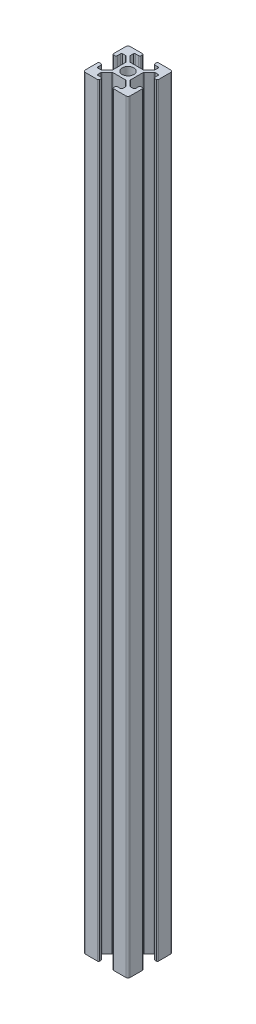
from build123d import *

# Parameters (mm, degrees)
SKETCH1_R           = 2.6
BOSS_EXTRUDE1_DEPTH = 340


with BuildPart() as part:
    # Sketch1 → Boss-Extrude1 (new body)
    with BuildSketch(Plane(origin=(0, 170, 0), x_dir=(1, 0, 0), z_dir=(0, 1, 0))):
        with BuildLine():
            Line((-3.1, 8.85), (-3.1, 9.5))
            ThreePointArc((-3.1, 9.5), (-3.246446609, 9.853553391), (-3.6, 10))
            Line((-3.6, 10), (-9, 10))
            ThreePointArc((-9, 10), (-9.707106781, 9.707106781), (-10, 9))
            Line((-10, 9), (-10, 3.6))
            ThreePointArc((-10, 3.6), (-9.853553391, 3.246446609), (-9.5, 3.1))
            Line((-9.5, 3.1), (-8.85, 3.1))
            ThreePointArc((-8.85, 3.1), (-8.496446609, 3.246446609), (-8.35, 3.6))
            Line((-8.35, 3.6), (-8.35, 5))
            ThreePointArc((-8.35, 5), (-8.203553391, 5.353553391), (-7.85, 5.5))
            Line((-7.85, 5.5), (-6.626345597, 5.5))
            ThreePointArc((-6.626345597, 5.5), (-6.435003881, 5.461939766), (-6.272792206, 5.353553391))
            Line((-6.272792206, 5.353553391), (-4.046446609, 3.127207794))
            ThreePointArc((-4.046446609, 3.127207794), (-3.938060234, 2.964996119), (-3.9, 2.773654403))
            Line((-3.9, 2.773654403), (-3.9, -2.773654403))
            ThreePointArc((-3.9, -2.773654403), (-3.938060234, -2.964996119), (-4.046446609, -3.127207794))
            Line((-4.046446609, -3.127207794), (-6.272792206, -5.353553391))
            ThreePointArc((-6.272792206, -5.353553391), (-6.435003881, -5.461939766), (-6.626345597, -5.5))
            Line((-6.626345597, -5.5), (-7.85, -5.5))
            ThreePointArc((-7.85, -5.5), (-8.203553391, -5.353553391), (-8.35, -5))
            Line((-8.35, -5), (-8.35, -3.6))
            ThreePointArc((-8.35, -3.6), (-8.496446609, -3.246446609), (-8.85, -3.1))
            Line((-8.85, -3.1), (-9.5, -3.1))
            ThreePointArc((-9.5, -3.1), (-9.853553391, -3.246446609), (-10, -3.6))
            Line((-10, -3.6), (-10, -9))
            ThreePointArc((-10, -9), (-9.707106781, -9.707106781), (-9, -10))
            Line((-9, -10), (-3.6, -10))
            ThreePointArc((-3.6, -10), (-3.246446609, -9.853553391), (-3.1, -9.5))
            Line((-3.1, -9.5), (-3.1, -8.85))
            ThreePointArc((-3.1, -8.85), (-3.246446609, -8.496446609), (-3.6, -8.35))
            Line((-3.6, -8.35), (-5, -8.35))
            ThreePointArc((-5, -8.35), (-5.353553391, -8.203553391), (-5.5, -7.85))
            Line((-5.5, -7.85), (-5.5, -6.626345597))
            ThreePointArc((-5.5, -6.626345597), (-5.461939766, -6.435003881), (-5.353553391, -6.272792206))
            Line((-5.353553391, -6.272792206), (-3.127207794, -4.046446609))
            ThreePointArc((-3.127207794, -4.046446609), (-2.964996119, -3.938060234), (-2.773654403, -3.9))
            Line((-2.773654403, -3.9), (2.773654403, -3.9))
            ThreePointArc((2.773654403, -3.9), (2.964996119, -3.938060234), (3.127207794, -4.046446609))
            Line((3.127207794, -4.046446609), (5.353553391, -6.272792206))
            ThreePointArc((5.353553391, -6.272792206), (5.461939766, -6.435003881), (5.5, -6.626345597))
            Line((5.5, -6.626345597), (5.5, -7.85))
            ThreePointArc((5.5, -7.85), (5.353553391, -8.203553391), (5, -8.35))
            Line((5, -8.35), (3.6, -8.35))
            ThreePointArc((3.6, -8.35), (3.246446609, -8.496446609), (3.1, -8.85))
            Line((3.1, -8.85), (3.1, -9.5))
            ThreePointArc((3.1, -9.5), (3.246446609, -9.853553391), (3.6, -10))
            Line((3.6, -10), (9, -10))
            ThreePointArc((9, -10), (9.707106781, -9.707106781), (10, -9))
            Line((10, -9), (10, -3.6))
            ThreePointArc((10, -3.6), (9.853553391, -3.246446609), (9.5, -3.1))
            Line((9.5, -3.1), (8.85, -3.1))
            ThreePointArc((8.85, -3.1), (8.496446609, -3.246446609), (8.35, -3.6))
            Line((8.35, -3.6), (8.35, -5))
            ThreePointArc((8.35, -5), (8.203553391, -5.353553391), (7.85, -5.5))
            Line((7.85, -5.5), (6.626345597, -5.5))
            ThreePointArc((6.626345597, -5.5), (6.435003881, -5.461939766), (6.272792206, -5.353553391))
            Line((6.272792206, -5.353553391), (4.046446609, -3.127207794))
            ThreePointArc((4.046446609, -3.127207794), (3.938060234, -2.964996119), (3.9, -2.773654403))
            Line((3.9, -2.773654403), (3.9, 2.773654403))
            ThreePointArc((3.9, 2.773654403), (3.938060234, 2.964996119), (4.046446609, 3.127207794))
            Line((4.046446609, 3.127207794), (6.272792206, 5.353553391))
            ThreePointArc((6.272792206, 5.353553391), (6.435003881, 5.461939766), (6.626345597, 5.5))
            Line((6.626345597, 5.5), (7.85, 5.5))
            ThreePointArc((7.85, 5.5), (8.203553391, 5.353553391), (8.35, 5))
            Line((8.35, 5), (8.35, 3.6))
            ThreePointArc((8.35, 3.6), (8.496446609, 3.246446609), (8.85, 3.1))
            Line((8.85, 3.1), (9.5, 3.1))
            ThreePointArc((9.5, 3.1), (9.853553391, 3.246446609), (10, 3.6))
            Line((10, 3.6), (10, 9))
            ThreePointArc((10, 9), (9.707106781, 9.707106781), (9, 10))
            Line((9, 10), (3.6, 10))
            ThreePointArc((3.6, 10), (3.246446609, 9.853553391), (3.1, 9.5))
            Line((3.1, 9.5), (3.1, 8.85))
            ThreePointArc((3.1, 8.85), (3.246446609, 8.496446609), (3.6, 8.35))
            Line((3.6, 8.35), (5, 8.35))
            ThreePointArc((5, 8.35), (5.353553391, 8.203553391), (5.5, 7.85))
            Line((5.5, 7.85), (5.5, 6.626345597))
            ThreePointArc((5.5, 6.626345597), (5.461939766, 6.435003881), (5.353553391, 6.272792206))
            Line((5.353553391, 6.272792206), (3.127207794, 4.046446609))
            ThreePointArc((3.127207794, 4.046446609), (2.964996119, 3.938060234), (2.773654403, 3.9))
            Line((2.773654403, 3.9), (-2.773654403, 3.9))
            ThreePointArc((-2.773654403, 3.9), (-2.964996119, 3.938060234), (-3.127207794, 4.046446609))
            Line((-3.127207794, 4.046446609), (-5.5, 6.419238816))
            Line((-5.5, 6.419238816), (-5.5, 7.85))
            ThreePointArc((-5.5, 7.85), (-5.353553391, 8.203553391), (-5, 8.35))
            Line((-5, 8.35), (-3.6, 8.35))
            ThreePointArc((-3.6, 8.35), (-3.246446609, 8.496446609), (-3.1, 8.85))
        make_face()
        Circle(SKETCH1_R, mode=Mode.SUBTRACT)
    extrude(amount=-BOSS_EXTRUDE1_DEPTH)


solid = part.part
